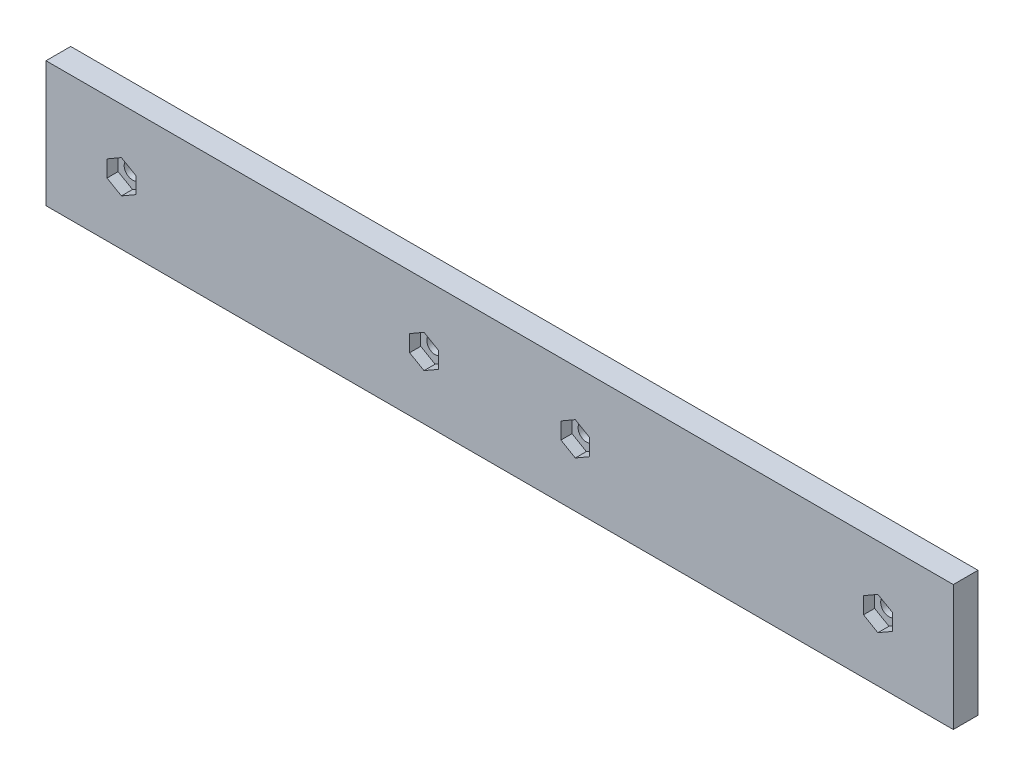
from build123d import *

# Parameters (mm, degrees)
SKETCH1_W           = 179.9
SKETCH1_H           = 24.9
SKETCH1_R           = 1.65
BOSS_EXTRUDE1_DEPTH = 4.9
CUT_EXTRUDE1_DEPTH  = 2.2


with BuildPart() as part:
    # Sketch1 → Boss-Extrude1 (new body)
    with BuildSketch(Plane.XY):
        with Locations((130.907132516, 5.230027325)):
            Rectangle(SKETCH1_W, SKETCH1_H)
        with Locations((205.907132516, 5.230027325)):
            Circle(SKETCH1_R, mode=Mode.SUBTRACT)
        with Locations((145.907132516, 5.230027325)):
            Circle(SKETCH1_R, mode=Mode.SUBTRACT)
        with Locations((115.907132516, 5.230027325)):
            Circle(SKETCH1_R, mode=Mode.SUBTRACT)
        with Locations((55.907132516, 5.230027325)):
            Circle(SKETCH1_R, mode=Mode.SUBTRACT)
    extrude(amount=BOSS_EXTRUDE1_DEPTH)

    # Sketch2 → Cut-Extrude1 (cut)
    with BuildSketch(Plane.XY.offset(4.9)):
        Polygon((58.757132516, 3.584579057), (58.757132516, 6.875475592), (55.907132516, 8.520923859), (53.057132516, 6.875475592), (53.057132516, 3.584579057), (55.907132516, 1.93913079), align=None)
        Polygon((118.757132516, 3.584579057), (118.757132516, 6.875475592), (115.907132516, 8.520923859), (113.057132516, 6.875475592), (113.057132516, 3.584579057), (115.907132516, 1.93913079), align=None)
        Polygon((148.757132516, 3.584579057), (148.757132516, 6.875475592), (145.907132516, 8.520923859), (143.057132516, 6.875475592), (143.057132516, 3.584579057), (145.907132516, 1.93913079), align=None)
        Polygon((208.757132516, 3.584579057), (208.757132516, 6.875475592), (205.907132516, 8.520923859), (203.057132516, 6.875475592), (203.057132516, 3.584579057), (205.907132516, 1.93913079), align=None)
    extrude(amount=-CUT_EXTRUDE1_DEPTH, mode=Mode.SUBTRACT)


solid = part.part
